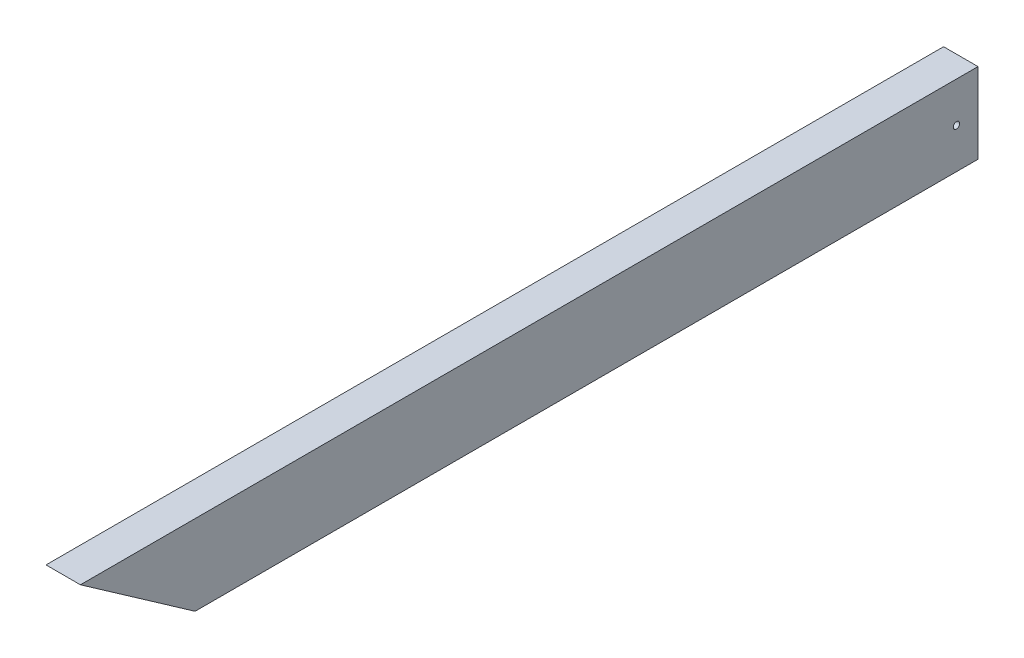
from build123d import *

# Parameters (mm, degrees)
SKETCH1_W                       = 38.1
SKETCH1_H                       = 88.9
BOSS_EXTRUDE1_DEPTH             = 1143
F_9_32_0_28125_DIAMETER_HOLE1_D = 7.14375
SKETCH5_R                       = 3.571875
CUT_EXTRUDE1_DEPTH              = 39.1


with BuildPart() as part:
    # Sketch1 → Boss-Extrude1 (new body)
    with BuildSketch(Plane.XY):
        Rectangle(SKETCH1_W, SKETCH1_H)
    extrude(amount=BOSS_EXTRUDE1_DEPTH)

    # 9/32 (0.28125) Diameter Hole1 (through all)
    with Locations(Plane(origin=(19.05, 0, 0), x_dir=(0, 0, -1), z_dir=(1, 0, 0))):
        with Locations((-1128.7125, 0), (-23.8125, 0)):
            Hole(F_9_32_0_28125_DIAMETER_HOLE1_D / 2)

    # Sketch5 → Cut-Extrude1 (cut, through all)
    with BuildSketch(Plane(origin=(19.05, 0, 0), x_dir=(0, 0, -1), z_dir=(1, 0, 0))):
        Polygon((-866.812642201, -44.45), (-993.775, 44.45), (-1143, 44.45), (-1143, -44.45), (-869.95, -44.45), align=None)
        with Locations((-1128.7125, 0)):
            Circle(SKETCH5_R, mode=Mode.SUBTRACT)
    extrude(amount=-CUT_EXTRUDE1_DEPTH, mode=Mode.SUBTRACT)


solid = part.part
